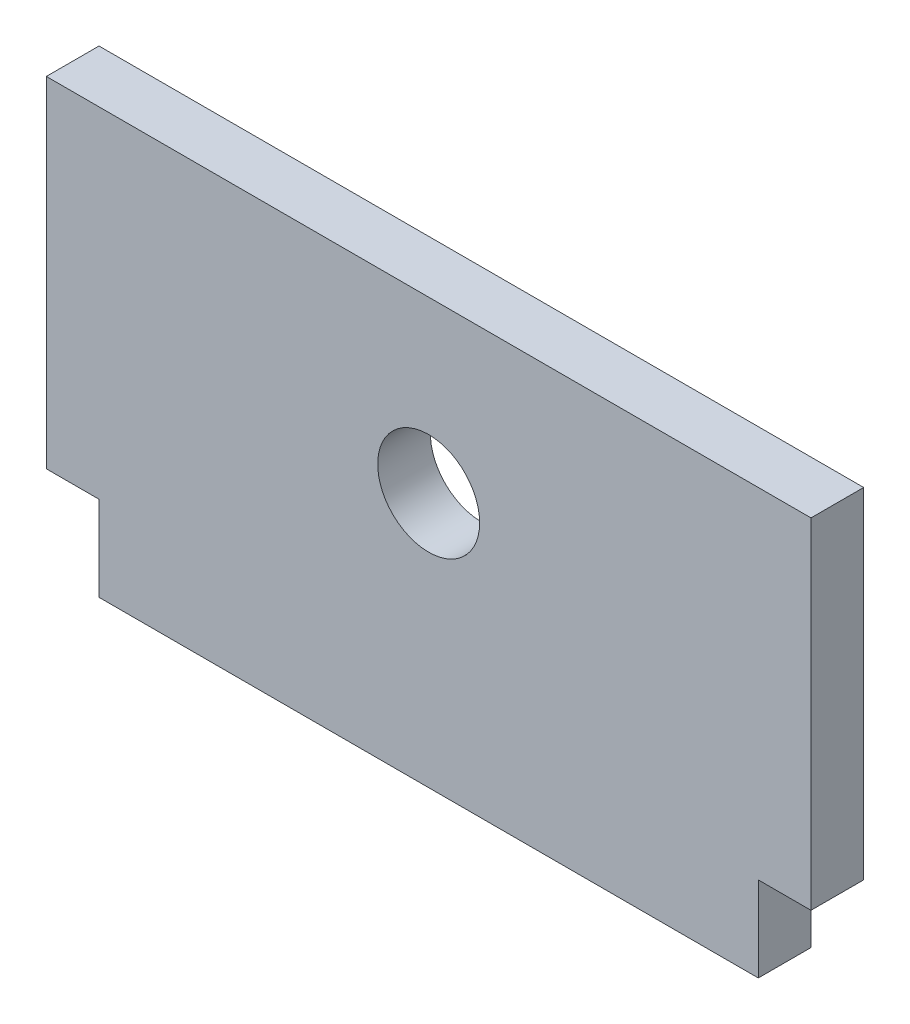
from build123d import *

# Parameters (mm, degrees)
SKETCH1_W           = 45
SKETCH1_H           = 20
SKETCH1_R           = 3
BOSS_EXTRUDE1_DEPTH = 3.1
SKETCH2_W           = 38.8
SKETCH2_H           = 5
BOSS_EXTRUDE2_DEPTH = 3.1


with BuildPart() as part:
    # Sketch1 → Boss-Extrude1 (new body)
    with BuildSketch(Plane.XY):
        Rectangle(SKETCH1_W, SKETCH1_H)
        Circle(SKETCH1_R, mode=Mode.SUBTRACT)
    extrude(amount=BOSS_EXTRUDE1_DEPTH)

    # Sketch2 → Boss-Extrude2 (add, through all)
    with BuildSketch(Plane.XY.offset(3.1)):
        with Locations((0, -12.5)):
            Rectangle(SKETCH2_W, SKETCH2_H)
    extrude(amount=-BOSS_EXTRUDE2_DEPTH)


solid = part.part
